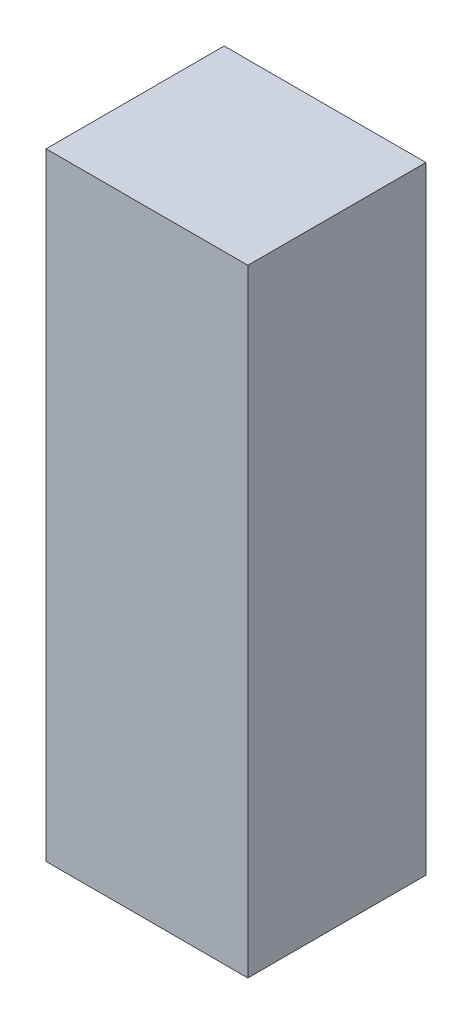
from build123d import *

# Parameters (mm, degrees)
SKETCH1_W           = 34
SKETCH1_H           = 30
BOSS_EXTRUDE1_DEPTH = 104


with BuildPart() as part:
    # Sketch1 → Boss-Extrude1 (new body)
    with BuildSketch(Plane(origin=(0, 0, 0), x_dir=(1, 0, 0), z_dir=(0, 1, 0))):
        Rectangle(SKETCH1_W, SKETCH1_H)
    extrude(amount=BOSS_EXTRUDE1_DEPTH)


solid = part.part
